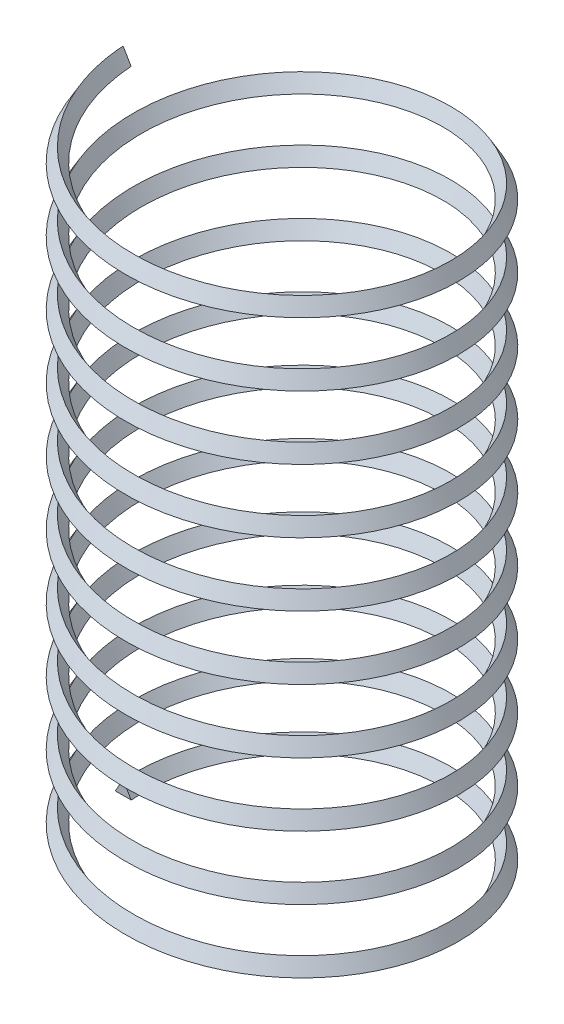
from build123d import *

# Parameters (mm, degrees)
SWEEP1_PITCH       = 20
SWEEP1_HEIGHT      = 200
SWEEP1_RADIUS      = 50
SWEEP1_START_ANGLE = -90


with BuildPart() as part:
    # Sweep1: sweep along a helix
    with BuildLine() as sweep1_path:
        add(Helix(SWEEP1_PITCH, SWEEP1_HEIGHT, SWEEP1_RADIUS, center=(0, 0, 0), direction=(0, 1, 0), lefthand=True, mode=Mode.PRIVATE).rotate(Axis((0, 0, 0), (0, 1, 0)), SWEEP1_START_ANGLE))
    # Sketch3 → Sweep1 (sweep)
    with BuildSketch(Plane.XY):
        Polygon((-50.008064385, 2.886740082), (-47.495977563, -1.436386078), (-52.495958052, -1.450354003), align=None)
    sweep(path=sweep1_path.line, is_frenet=True)


solid = part.part
